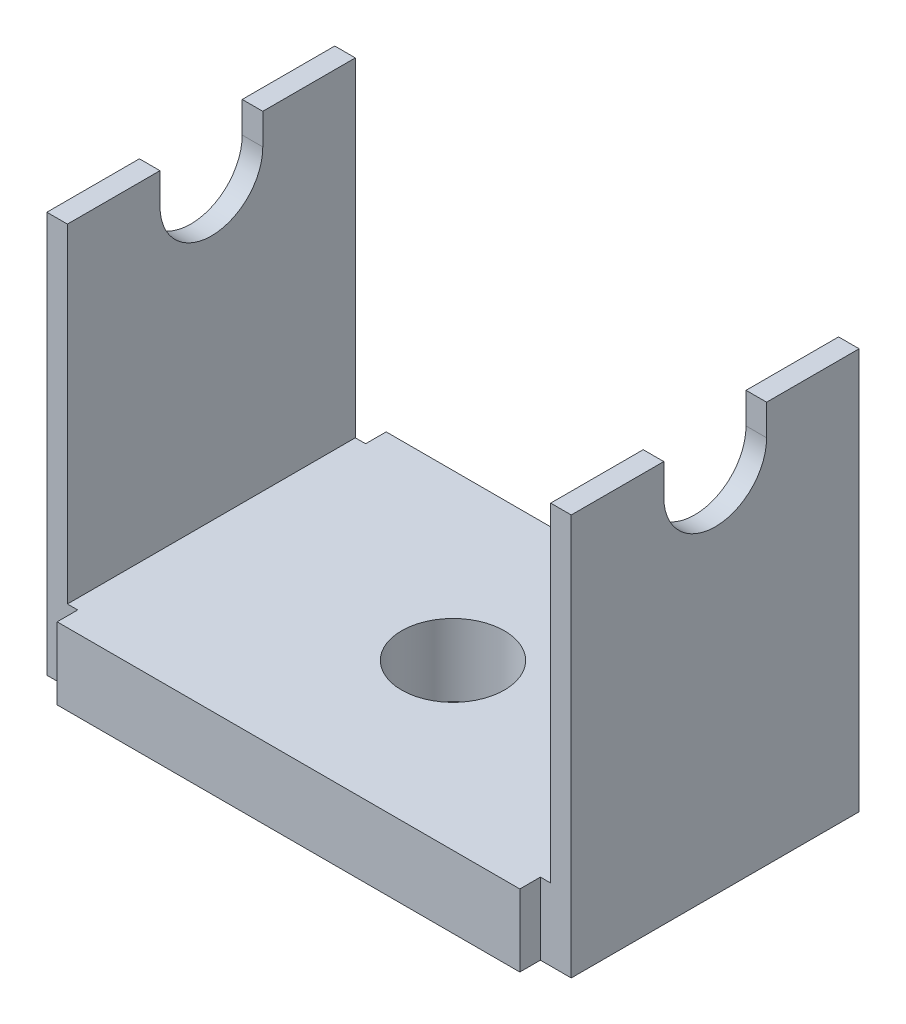
from build123d import *

# Parameters (mm, degrees)
BOSS_EXTRUDE1_DEPTH = 14
BOSS_EXTRUDE2_DEPTH = 22.5
CUT_EXTRUDE1_DEPTH  = 52
SKETCH4_R           = 5
CUT_EXTRUDE2_DEPTH  = 8


with BuildPart() as part:
    # Sketch1 → Boss-Extrude1 (new body, symmetric)
    with BuildSketch(Plane.XY):
        Polygon((-25.5, 3), (-25.5, -36), (25.5, -36), (25.5, 3), (23.5, 3), (23.5, -29), (-23.5, -29), (-23.5, 3), align=None)
    extrude(amount=BOSS_EXTRUDE1_DEPTH, both=True)

    # Sketch2 → Boss-Extrude2 (add, symmetric)
    with BuildSketch(Plane(origin=(0, 0, 0), x_dir=(0, 0, -1), z_dir=(1, 0, 0))):
        Polygon((-14, -36), (-16, -36), (-16, -29), (-13, -29), (-13, -33), (-14, -33), align=None)
    boss_extrude2 = extrude(amount=BOSS_EXTRUDE2_DEPTH, both=True)

    # Mirror1: Boss-Extrude2 across plane
    add(boss_extrude2.mirror(Plane.XY))

    # Sketch3 → Cut-Extrude1 (cut, through all)
    with BuildSketch(Plane(origin=(25.5, 0, 0), x_dir=(0, 0, -1), z_dir=(1, 0, 0))):
        with BuildLine():
            Line((-5, 0), (-5, 3))
            Line((-5, 3), (5, 3))
            Line((5, 3), (5, 0))
            ThreePointArc((5, 0), (0, -5), (-5, 0))
        make_face()
    extrude(amount=-CUT_EXTRUDE1_DEPTH, mode=Mode.SUBTRACT)

    # Sketch4 → Cut-Extrude2 (cut, through all)
    with BuildSketch(Plane(origin=(0, -29, 0), x_dir=(1, 0, 0), z_dir=(0, 1, 0))):
        Circle(SKETCH4_R)
    extrude(amount=-CUT_EXTRUDE2_DEPTH, mode=Mode.SUBTRACT)


solid = part.part
